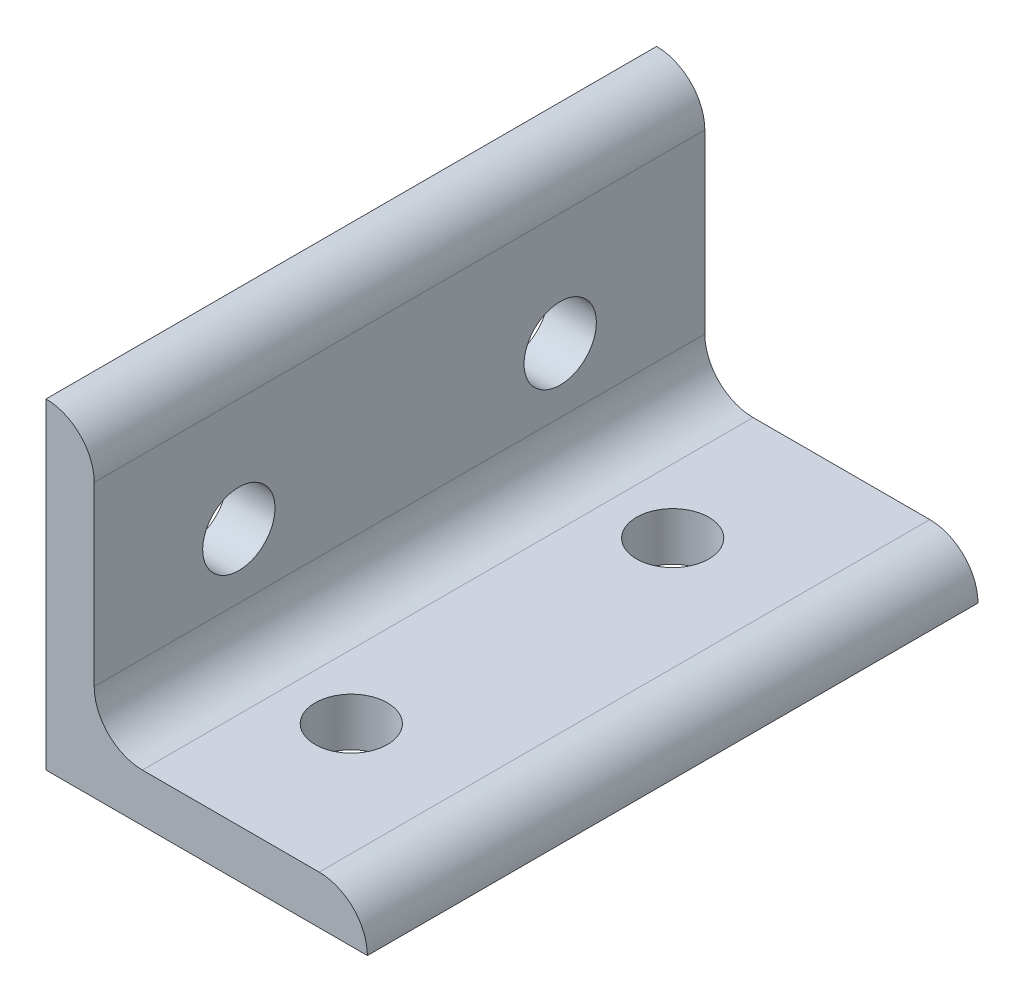
from build123d import *

# Parameters (mm, degrees)
BOSS_EXTRUDE1_DEPTH = 38
SKETCH2_R           = 4.5
CUT_EXTRUDE1_DEPTH  = 41
SKETCH3_R           = 4.5
CUT_EXTRUDE2_DEPTH  = 41


with BuildPart() as part:
    # Sketch1 → Boss-Extrude1 (new body, symmetric)
    with BuildSketch(Plane.XY):
        with BuildLine():
            Line((0, 0), (0, 40))
            ThreePointArc((0, 40), (4.242640687, 38.242640687), (6, 34))
            Line((6, 34), (6, 12))
            ThreePointArc((6, 12), (7.757359313, 7.757359313), (12, 6))
            Line((12, 6), (34, 6))
            ThreePointArc((34, 6), (38.242640687, 4.242640687), (40, 0))
            Line((40, 0), (0, 0))
        make_face()
    extrude(amount=BOSS_EXTRUDE1_DEPTH, both=True)

    # Sketch2 → Cut-Extrude1 (cut, through all)
    with BuildSketch(Plane(origin=(0, 0, 0), x_dir=(1, 0, 0), z_dir=(0, 1, 0))):
        with Locations((20, -20)):
            Circle(SKETCH2_R)
        with Locations((20, 20)):
            Circle(SKETCH2_R)
    extrude(amount=CUT_EXTRUDE1_DEPTH, mode=Mode.SUBTRACT)

    # Sketch3 → Cut-Extrude2 (cut, through all)
    with BuildSketch(Plane(origin=(0, 0, 0), x_dir=(0, 0, -1), z_dir=(1, 0, 0))):
        with Locations((-20, 20)):
            Circle(SKETCH3_R)
        with Locations((20, 20)):
            Circle(SKETCH3_R)
    extrude(amount=CUT_EXTRUDE2_DEPTH, mode=Mode.SUBTRACT)


solid = part.part
